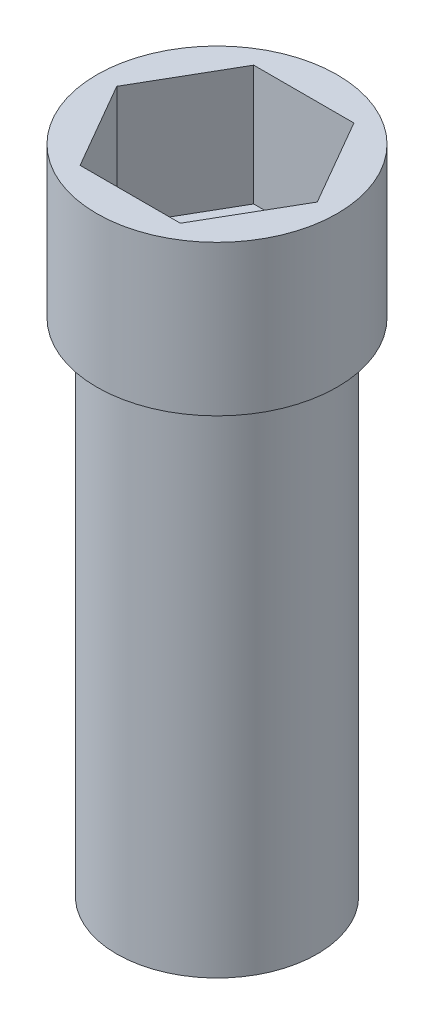
from build123d import *

# Parameters (mm, degrees)
SKETCH1_R           = 254
BOSS_EXTRUDE1_DEPTH = 1270
SKETCH2_R           = 304.8
BOSS_EXTRUDE2_DEPTH = 381
CUT_EXTRUDE1_DEPTH  = 304.8
SKETCH4_W           = 152.4
SKETCH4_H           = 635
CUT_EXTRUDE2_DEPTH  = 101.6


with BuildPart() as part:
    # Sketch1 → Boss-Extrude1 (new body)
    with BuildSketch(Plane(origin=(0, 0, 0), x_dir=(1, 0, 0), z_dir=(0, 1, 0))):
        Circle(SKETCH1_R)
    extrude(amount=-BOSS_EXTRUDE1_DEPTH)

    # Sketch2 → Boss-Extrude2 (add)
    with BuildSketch(Plane(origin=(0, 0, 0), x_dir=(1, 0, 0), z_dir=(0, 1, 0))):
        Circle(SKETCH2_R)
    extrude(amount=BOSS_EXTRUDE2_DEPTH)

    # Sketch3 → Cut-Extrude1 (cut)
    with BuildSketch(Plane(origin=(0, 381, 0), x_dir=(1, 0, 0), z_dir=(0, 1, 0))):
        Polygon((-127.035376657, 220.031726729), (127.035376657, 220.031726729), (254.070753314, 0), (127.035376657, -220.031726729), (-127.035376657, -220.031726729), (-254.070753314, 0), align=None)
    extrude(amount=-CUT_EXTRUDE1_DEPTH, mode=Mode.SUBTRACT)

    # Sketch4 → Cut-Extrude2 (cut)
    with BuildSketch(Plane.XY.offset(-254)):
        with Locations((0, -508)):
            Rectangle(SKETCH4_W, SKETCH4_H)
    extrude(amount=CUT_EXTRUDE2_DEPTH, mode=Mode.SUBTRACT)


solid = part.part
